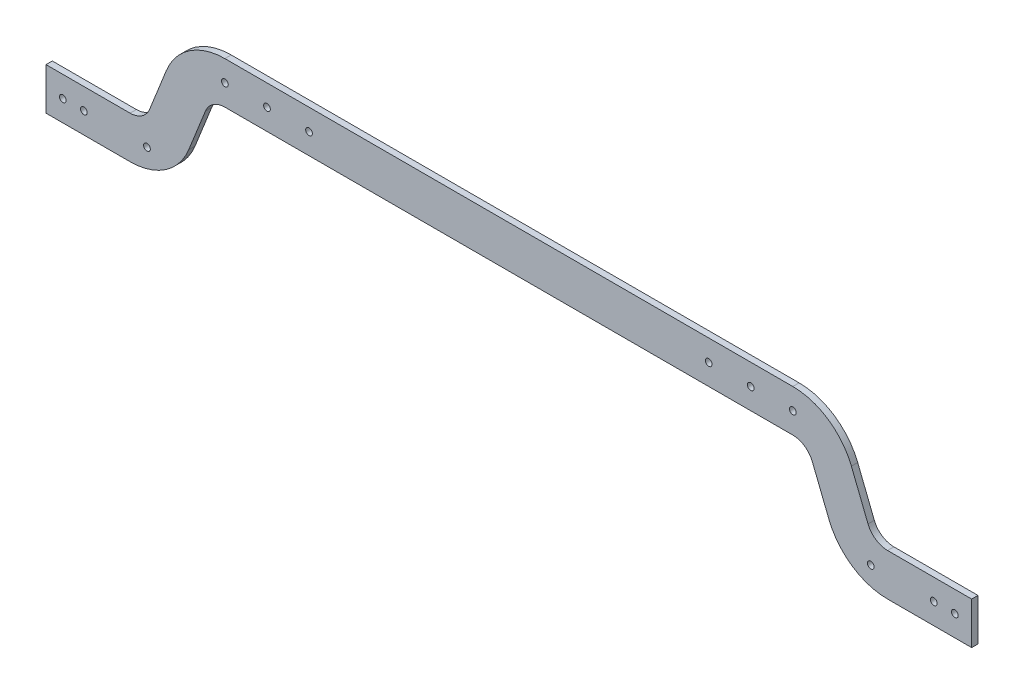
from build123d import *

# Parameters (mm, degrees)
EXTRUDE1_DEPTH     = 3
SKETCH2_R          = 1.6
CUT_EXTRUDE1_DEPTH = 3


with BuildPart() as part:
    # Sketch1 → Extrude1 (new body)
    with BuildSketch(Plane.XY):
        with BuildLine():
            Line((-512.555561166, 145), (-472.555561166, 145))
            ThreePointArc((-472.555561166, 145), (-455.723951498, 150.166616904), (-444.689840432, 163.886872268))
            Line((-444.689840432, 163.886872268), (-436.785621791, 183.706382542))
            ThreePointArc((-436.785621791, 183.706382542), (-433.10758477, 188.279800996), (-427.497048214, 190.002006631))
            Line((-427.497048214, 190.002006631), (-157.497048214, 190.002006631))
            ThreePointArc((-157.497048214, 190.002006631), (-151.886511658, 188.279800996), (-148.208474636, 183.706382542))
            Line((-148.208474636, 183.706382542), (-140.304255995, 163.886872268))
            ThreePointArc((-140.304255995, 163.886872268), (-129.270144929, 150.166616904), (-112.438535261, 145))
            Line((-112.438535261, 145), (-72.438535261, 145))
            Line((-72.438535261, 145), (-72.438535261, 165))
            Line((-72.438535261, 165), (-112.438535261, 165))
            ThreePointArc((-112.438535261, 165), (-118.049071817, 166.722205635), (-121.727108839, 171.295624089))
            Line((-121.727108839, 171.295624089), (-129.63132748, 191.115134363))
            ThreePointArc((-129.63132748, 191.115134363), (-140.665438546, 204.835389727), (-157.497048214, 210.002006631))
            Line((-157.497048214, 210.002006631), (-427.497048214, 210.002006631))
            ThreePointArc((-427.497048214, 210.002006631), (-444.328657882, 204.835389727), (-455.362768947, 191.115134363))
            Line((-455.362768947, 191.115134363), (-463.266987588, 171.295624089))
            ThreePointArc((-463.266987588, 171.295624089), (-466.94502461, 166.722205635), (-472.555561166, 165))
            Line((-472.555561166, 165), (-512.555561166, 165))
            Line((-512.555561166, 165), (-512.555561166, 145))
        make_face()
    extrude(amount=EXTRUDE1_DEPTH)

    # Sketch2 → Cut-Extrude1 (cut)
    with BuildSketch(Plane.XY.offset(3)):
        with Locations((-494.555561166, 155)):
            Circle(SKETCH2_R)
        with Locations((-464.555561166, 155)):
            Circle(SKETCH2_R)
        with Locations((-427.497048214, 200.002006631)):
            Circle(SKETCH2_R)
        with Locations((-407.497048214, 199.95245399)):
            Circle(SKETCH2_R)
        with Locations((-387.497048214, 199.90290135)):
            Circle(SKETCH2_R)
        with Locations((-504.555561166, 155)):
            Circle(SKETCH2_R)
        with Locations((-80.438535261, 155)):
            Circle(SKETCH2_R)
        with Locations((-197.497048214, 199.90290135)):
            Circle(SKETCH2_R)
        with Locations((-177.497048214, 199.95245399)):
            Circle(SKETCH2_R)
        with Locations((-157.497048214, 200.002006631)):
            Circle(SKETCH2_R)
        with Locations((-120.438535261, 155)):
            Circle(SKETCH2_R)
        with Locations((-90.438535261, 155)):
            Circle(SKETCH2_R)
    extrude(amount=-CUT_EXTRUDE1_DEPTH, mode=Mode.SUBTRACT)


solid = part.part
